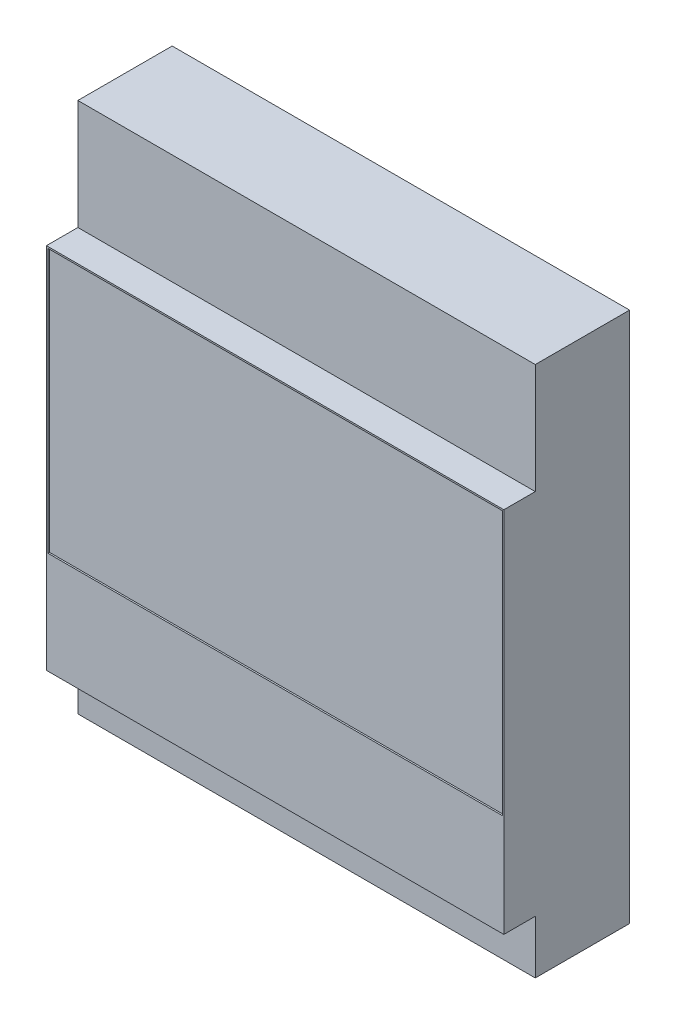
from build123d import *

# Parameters (mm, degrees)
SKETCH_1_W          = 14.55
SKETCH_1_H          = 11.7
EXTRUDE_1_DEPTH     = 1
SKETCH_2_W          = 14.45
SKETCH_2_H          = 8.4
CUT_EXTRUDE_1_DEPTH = 0.05
SKETCH_3_W          = 14.55
SKETCH_3_H          = 16.9
EXTRUDE_2_DEPTH     = 3


with BuildPart() as part:
    # Эскиз1 → Бобышка-Вытянуть1 (new body)
    with BuildSketch(Plane.XY):
        Rectangle(SKETCH_1_W, SKETCH_1_H)
    extrude(amount=EXTRUDE_1_DEPTH)

    # Эскиз2 → Вырез-Вытянуть1 (cut)
    with BuildSketch(Plane.XY.offset(1)):
        with Locations((0, 1.6)):
            Rectangle(SKETCH_2_W, SKETCH_2_H)
    extrude(amount=-CUT_EXTRUDE_1_DEPTH, mode=Mode.SUBTRACT)

    # Эскиз3 → Бобышка-Вытянуть2 (add)
    with BuildSketch(Plane(origin=(0, 0, 0), x_dir=(-1, 0, 0), z_dir=(0, 0, -1))):
        with Locations((0, 0.9)):
            Rectangle(SKETCH_3_W, SKETCH_3_H)
    extrude(amount=EXTRUDE_2_DEPTH)


solid = part.part
